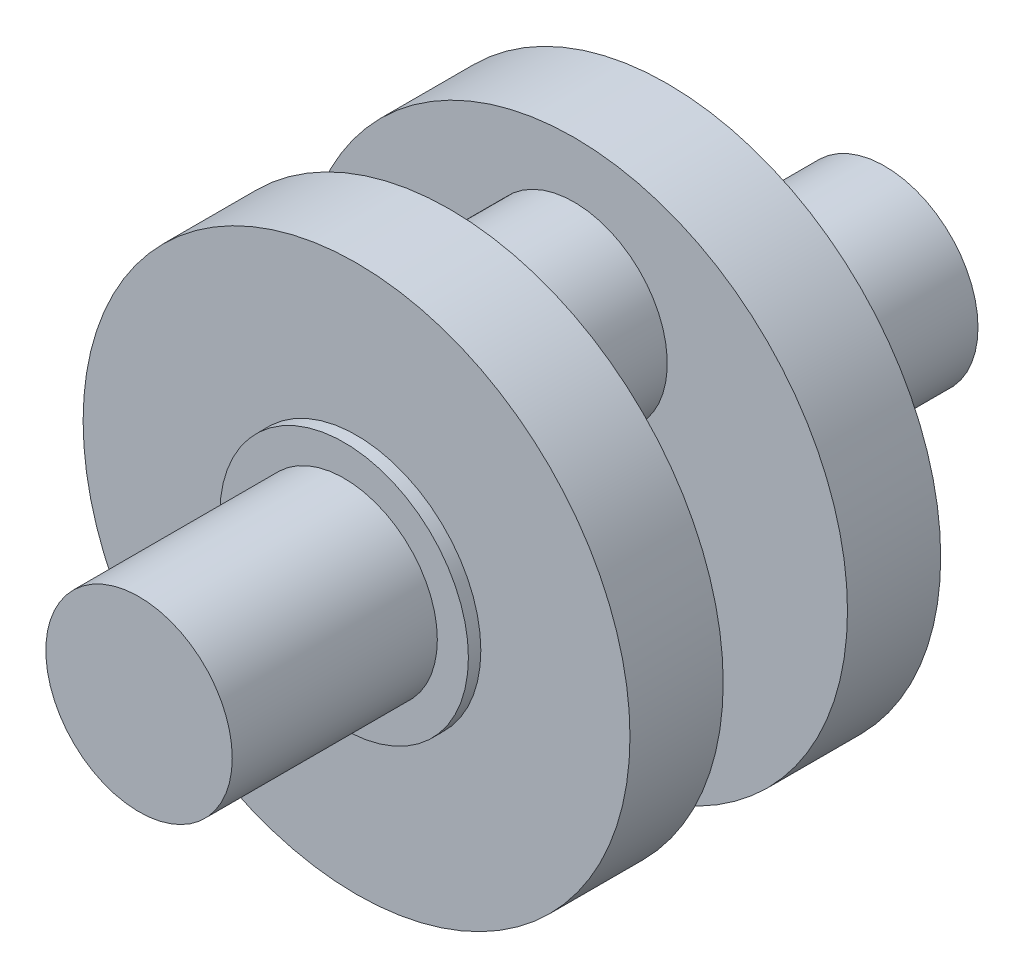
from build123d import *

# Parameters (mm, degrees)
SZKIC1_R                    = 15
DODANIE_WYCI_GNI_CIE1_DEPTH = 33
SZKIC2_R                    = 20
DODANIE_WYCI_GNI_CIE2_DEPTH = 2
SZKIC3_R                    = 44
DODANIE_WYCI_GNI_CIE3_DEPTH = 15
SZKIC4_R                    = 15
DODANIE_WYCI_GNI_CIE4_DEPTH = 10


with BuildPart() as part:
    # Szkic1 → Dodanie-wyciągnięcie1 (new body)
    with BuildSketch(Plane.XY):
        Circle(SZKIC1_R)
    extrude(amount=DODANIE_WYCI_GNI_CIE1_DEPTH)

    # Szkic2 → Dodanie-wyciągnięcie2 (add)
    with BuildSketch(Plane(origin=(0, 0, 0), x_dir=(-1, 0, 0), z_dir=(0, 0, -1))):
        Circle(SZKIC2_R)
    extrude(amount=DODANIE_WYCI_GNI_CIE2_DEPTH)

    # Szkic3 → Dodanie-wyciągnięcie3 (add)
    with BuildSketch(Plane(origin=(0, 0, -2), x_dir=(-1, 0, 0), z_dir=(0, 0, -1))):
        Circle(SZKIC3_R)
    extrude(amount=DODANIE_WYCI_GNI_CIE3_DEPTH)

    # Szkic4 → Dodanie-wyciągnięcie4 (add)
    with BuildSketch(Plane(origin=(0, 0, -17), x_dir=(-1, 0, 0), z_dir=(0, 0, -1))):
        with Locations((0, 20)):
            Circle(SZKIC4_R)
    extrude(amount=DODANIE_WYCI_GNI_CIE4_DEPTH)

    # Lustro1: part across plane


with BuildPart() as part_1:
    add(part.part)
    add(part.part.mirror(Plane(origin=(0, 20, -27), x_dir=(1, 0, 0), z_dir=(0, 0, -1))))


solid = part_1.part
